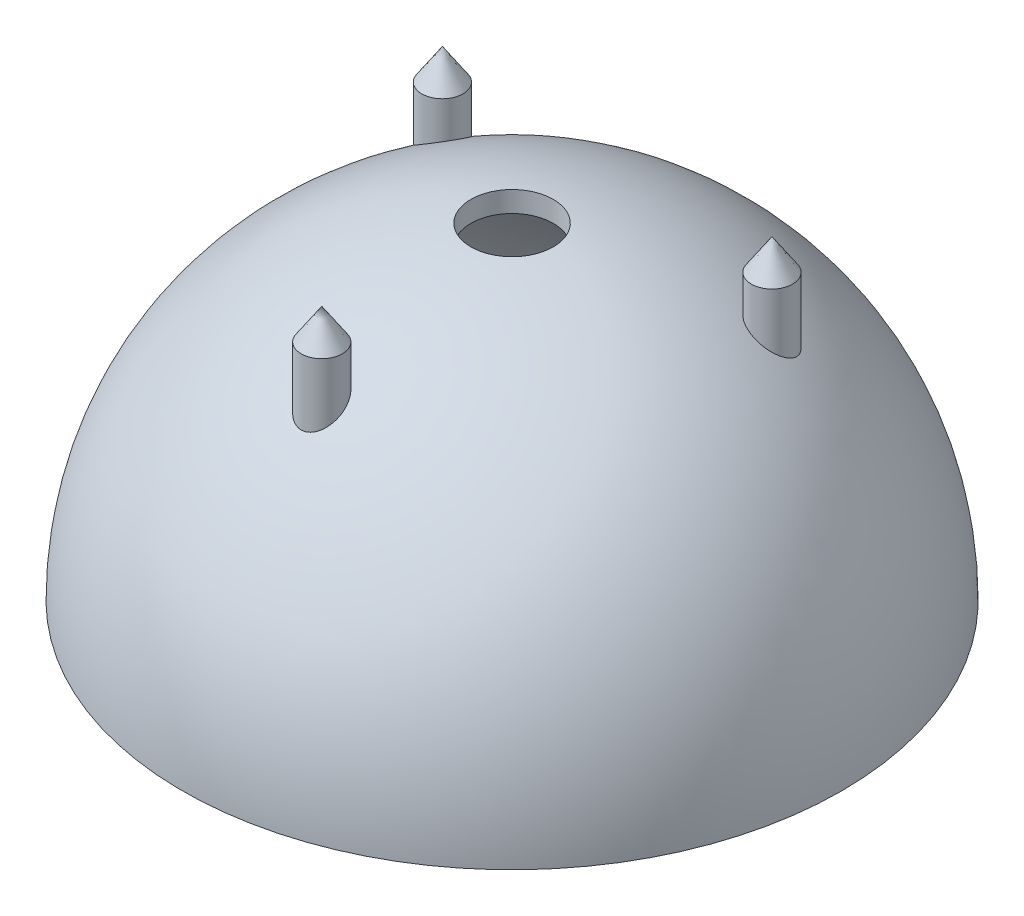
from build123d import *

# Parameters (mm, degrees)
EXTRUDE1_REACH    = 41.37
SKETCH2_R         = 2.54
SKETCH4_R         = 5.08
EXTRUDE3_DEPTH    = 41.64
CIRPATTERN1_COUNT = 3


with BuildPart() as part:
    # Sketch1 → Revolve1 (revolve)
    with BuildSketch(Plane.XY):
        with BuildLine():
            Line((38.1, 0), (40.64, 0))
            ThreePointArc((40.64, 0), (28.736819587, 28.736819587), (0, 40.64))
            Line((0, 40.64), (0, 38.1))
            ThreePointArc((0, 38.1), (26.940768363, 26.940768363), (38.1, 0))
        make_face()
    revolve(axis=Axis((0, 38.1, 0), (0, 1, 0)))

    # Sketch2 → Extrude1 (add, up to next)
    with BuildSketch(Plane.XZ.offset(-39.37), mode=Mode.PRIVATE) as extrude1_sk1:
        with Locations((0, 23.46351494)):
            Circle(SKETCH2_R)
    extrude1_tool1 = extrude(extrude1_sk1.sketch, amount=EXTRUDE1_REACH, mode=Mode.PRIVATE) - part.part
    add(extrude1_tool1.solids().sort_by_distance((0, 39.37, 23.463515))[0])
    # Sketch2 → Extrude1 (add, up to next)
    with BuildSketch(Plane.XZ.offset(-39.37), mode=Mode.PRIVATE) as extrude1_sk2:
        with Locations((-20.32, -11.73175747)):
            Circle(SKETCH2_R)
    extrude1_tool2 = extrude(extrude1_sk2.sketch, amount=EXTRUDE1_REACH, mode=Mode.PRIVATE) - part.part
    add(extrude1_tool2.solids().sort_by_distance((-20.32, 39.37, -11.731757))[0])
    # Sketch2 → Extrude1 (add, up to next)
    with BuildSketch(Plane.XZ.offset(-39.37), mode=Mode.PRIVATE) as extrude1_sk3:
        with Locations((20.32, -11.73175747)):
            Circle(SKETCH2_R)
    extrude1_tool3 = extrude(extrude1_sk3.sketch, amount=EXTRUDE1_REACH, mode=Mode.PRIVATE) - part.part
    add(extrude1_tool3.solids().sort_by_distance((20.32, 39.37, -11.731757))[0])

    # Sketch4 → Extrude3 (cut, through all)
    with BuildSketch(Plane.XZ):
        Circle(SKETCH4_R)
    extrude(amount=-EXTRUDE3_DEPTH, mode=Mode.SUBTRACT)

    # Sketch5 → Revolve2 (revolve)
    with BuildSketch(Plane(origin=(0, 0, 0), x_dir=(0, 0, -1), z_dir=(1, 0, 0))):
        Polygon((-20.92351494, 39.37), (-23.46351494, 43.18), (-23.46351494, 39.37), align=None)
    revolve2 = revolve(axis=Axis((0, 39.37, 23.46351494), (0, 1, 0)))

    # CirPattern1: Revolve2 ×3 about axis
    cirpattern1_axis = Axis((0, 0, 0), (0, 1, 0))
    for i in range(1, CIRPATTERN1_COUNT):
        add(revolve2.rotate(cirpattern1_axis, i * 360 / CIRPATTERN1_COUNT))


solid = part.part
